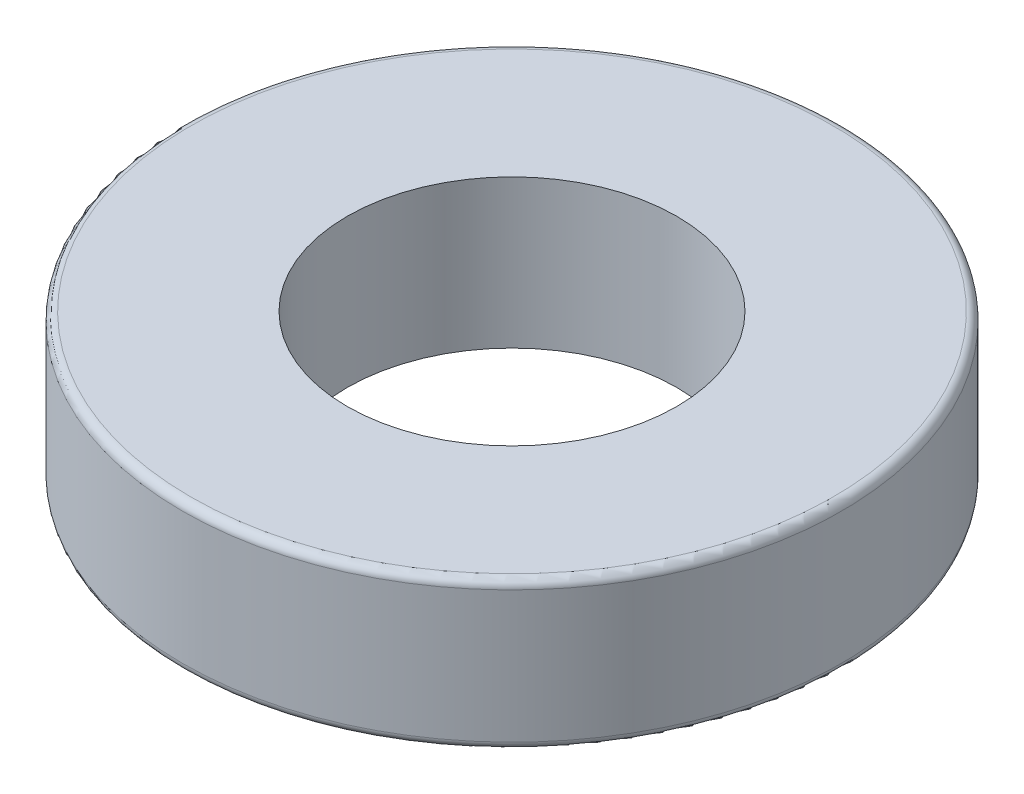
from build123d import *

# Parameters (mm, degrees)
SKETCH1_R           = 40
SKETCH1_R_2         = 20
BOSS_EXTRUDE1_DEPTH = 18
FILLET1_R           = 1


with BuildPart() as part:
    # Sketch1 → Boss-Extrude1 (new body)
    with BuildSketch(Plane(origin=(0, 0, 0), x_dir=(1, 0, 0), z_dir=(0, 1, 0))):
        Circle(SKETCH1_R)
        Circle(SKETCH1_R_2, mode=Mode.SUBTRACT)
    extrude(amount=BOSS_EXTRUDE1_DEPTH)

    # Fillet1
    fillet1_edges = [part.edges().sort_by_distance(p)[0] for p in [
        (-40, 0, 0),
        (-40, 18, 0),
    ]]
    fillet(fillet1_edges, radius=FILLET1_R)


solid = part.part
